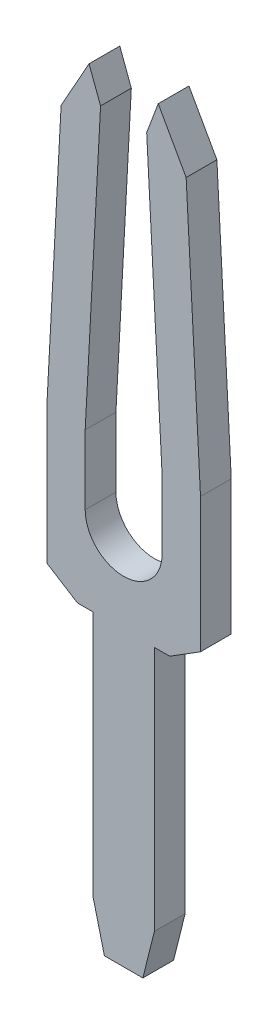
from build123d import *

# Parameters (mm, degrees)
DODANIE_WYCI_GNI_CIE1_DEPTH = 0.4


with BuildPart() as part:
    # Szkic1 → Dodanie-wyciągnięcie1 (new body)
    with BuildSketch(Plane.XY):
        with BuildLine():
            Line((0.25, -4.975), (0.4, -4.375))
            Line((0.4, -4.375), (0.4, -1.175))
            Line((0.4, -1.175), (0.6, -1.175))
            Line((0.6, -1.175), (1, -0.925))
            Line((1, -0.925), (1, 0.825))
            Line((1, 0.825), (0.813333333, 4.325))
            Line((0.813333333, 4.325), (0.45, 4.975))
            Line((0.45, 4.975), (0.3, 4.575))
            Line((0.3, 4.575), (0.5, 0.825))
            Line((0.5, 0.825), (0.5, -0.075))
            ThreePointArc((0.5, -0.075), (0, -0.575), (-0.5, -0.075))
            Line((-0.5, -0.075), (-0.5, 0.825))
            Line((-0.5, 0.825), (-0.3, 4.575))
            Line((-0.3, 4.575), (-0.45, 4.975))
            Line((-0.45, 4.975), (-0.813333333, 4.325))
            Line((-0.813333333, 4.325), (-1, 0.825))
            Line((-1, 0.825), (-1, -0.925))
            Line((-1, -0.925), (-0.6, -1.175))
            Line((-0.6, -1.175), (-0.4, -1.175))
            Line((-0.4, -1.175), (-0.4, -4.375))
            Line((-0.4, -4.375), (-0.25, -4.975))
            Line((-0.25, -4.975), (0.25, -4.975))
        make_face()
    extrude(amount=DODANIE_WYCI_GNI_CIE1_DEPTH)


solid = part.part
